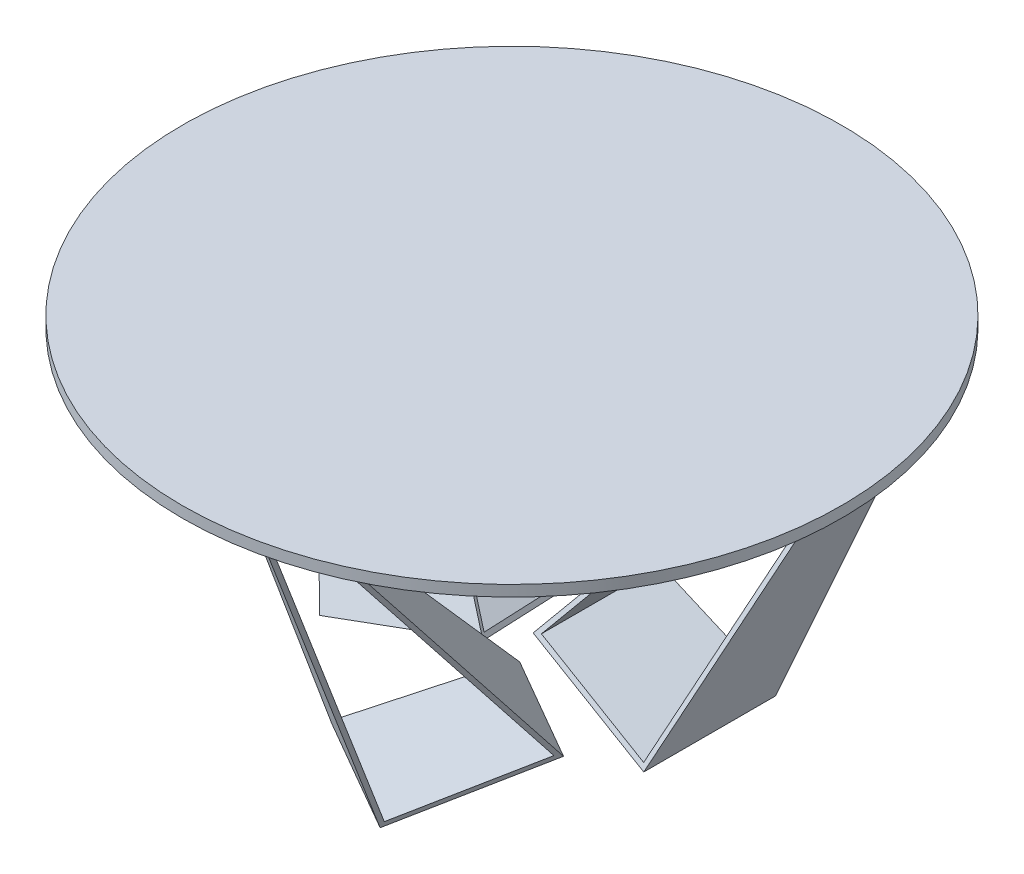
from build123d import *

# Parameters (mm, degrees)
SALIENTE_EXTRUIR1_DEPTH    = 500
CROQUIS2_OUTSIDE_W         = 708.788
CROQUIS2_OUTSIDE_H         = 933.788
CORTAR_EXTRUIR2_DEPTH      = 650
CORTAR_EXTRUIR2_DEPTH_BACK = 50
VACIADO2_T                 = -10
MATRIZC1_COUNT             = 3
SALIENTE_EXTRUIR2_START    = 725
CROQUIS5_R                 = 750
SALIENTE_EXTRUIR2_DEPTH    = 25


with BuildPart() as part:
    # Croquis1 → Saliente-Extruir1 (new body)
    with BuildSketch(Plane.XY):
        Polygon((300, 0), (541.666666667, 725), (466.666666667, 725), (0, 100), align=None)
    extrude(amount=-SALIENTE_EXTRUIR1_DEPTH)

    # Croquis2 outside → Cortar-Extruir2 (cut, two sides)
    with BuildSketch(Plane(origin=(0, 0, 0), x_dir=(0, 0, -1), z_dir=(1, 0, 0))) as cortar_extruir2_sk:
        with Locations((250, 362.5)):
            Rectangle(CROQUIS2_OUTSIDE_W, CROQUIS2_OUTSIDE_H)
        Polygon((0, 0), (350, 725), (450, 725), (300, 0), align=None, mode=Mode.SUBTRACT)
    extrude(amount=CORTAR_EXTRUIR2_DEPTH, mode=Mode.SUBTRACT)
    extrude(cortar_extruir2_sk.sketch, amount=-CORTAR_EXTRUIR2_DEPTH_BACK, mode=Mode.SUBTRACT)

    # Vaciado2
    vaciado2_openings = [part.faces().sort_by_distance(p)[0] for p in [
        (289.580826314, 314.259927798, -365.019295406),
        (289.580826314, 314.259927798, -151.711689282),
    ]]
    offset(amount=VACIADO2_T, openings=vaciado2_openings, kind=Kind.INTERSECTION)


with BuildPart() as matrizc1_1:
    # MatrizC1: pattern copy
    add(part.part.rotate(Axis((0, 0, 0), (0, 1, 0)), 1 * 360 / MATRIZC1_COUNT))


with BuildPart() as matrizc1_2:
    # MatrizC1: pattern copy
    add(part.part.rotate(Axis((0, 0, 0), (0, 1, 0)), 2 * 360 / MATRIZC1_COUNT))


with BuildPart() as body_4:
    # Croquis5 → Saliente-Extruir2 (new body)
    with BuildSketch(Plane(origin=(0, 0, 0), x_dir=(1, 0, 0), z_dir=(0, 1, 0)).offset(SALIENTE_EXTRUIR2_START)):
        with Locations(Location((0, 0, 0), (0, 0, 270))):  # turned: the seam where the file's is
            Circle(CROQUIS5_R)
    extrude(amount=SALIENTE_EXTRUIR2_DEPTH)


solid = Compound([part.part, matrizc1_1.part, matrizc1_2.part, body_4.part])
